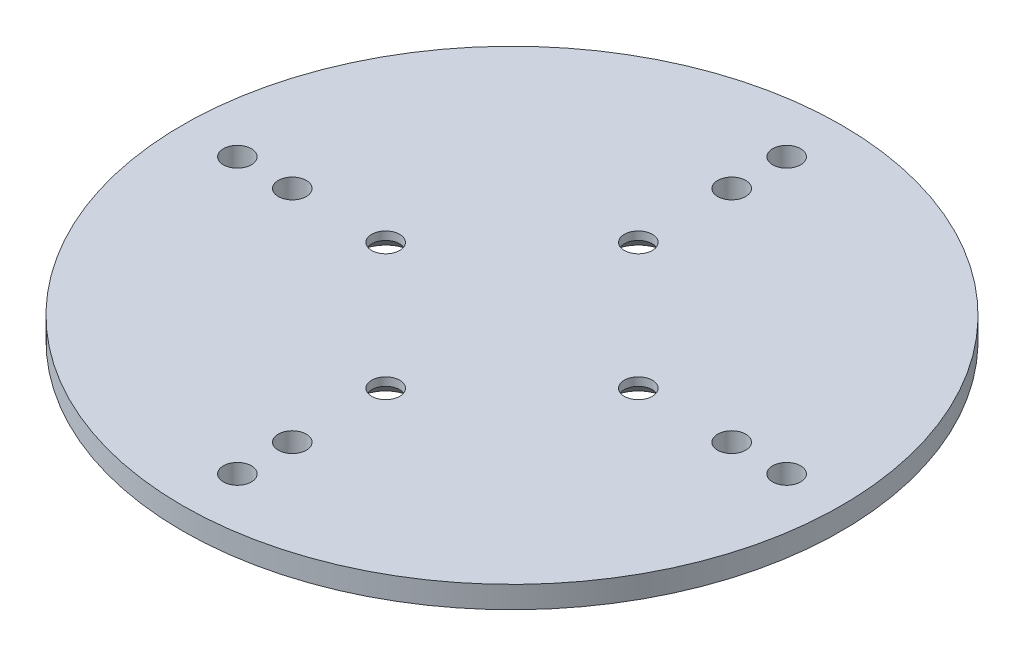
from build123d import *

# Parameters (mm, degrees)
SKETCH_1_R      = 60
SKETCH_1_R_2    = 2.55
EXTRUDE_1_DEPTH = 4
CHAMFER_1_SIZE  = 2.5


with BuildPart() as part:
    # 草图1 → 凸台-拉伸1 (new body)
    with BuildSketch(Plane(origin=(0, 0, 0), x_dir=(1, 0, 0), z_dir=(0, 1, 0))):
        Circle(SKETCH_1_R)
        with Locations((0, 50)):
            Circle(SKETCH_1_R_2, mode=Mode.SUBTRACT)
        with Locations((50, 0)):
            Circle(SKETCH_1_R_2, mode=Mode.SUBTRACT)
        with Locations((0, -50)):
            Circle(SKETCH_1_R_2, mode=Mode.SUBTRACT)
        with Locations((-50, 0)):
            Circle(SKETCH_1_R_2, mode=Mode.SUBTRACT)
        with Locations((0, 40)):
            Circle(SKETCH_1_R_2, mode=Mode.SUBTRACT)
        with Locations((40, 0)):
            Circle(SKETCH_1_R_2, mode=Mode.SUBTRACT)
        with Locations((0, -40)):
            Circle(SKETCH_1_R_2, mode=Mode.SUBTRACT)
        with Locations((-40, 0)):
            Circle(SKETCH_1_R_2, mode=Mode.SUBTRACT)
        with Locations((0, 23)):
            Circle(SKETCH_1_R_2, mode=Mode.SUBTRACT)
        with Locations((23, 0)):
            Circle(SKETCH_1_R_2, mode=Mode.SUBTRACT)
        with Locations((0, -23)):
            Circle(SKETCH_1_R_2, mode=Mode.SUBTRACT)
        with Locations((-23, 0)):
            Circle(SKETCH_1_R_2, mode=Mode.SUBTRACT)
    extrude(amount=EXTRUDE_1_DEPTH)

    # 倒角1
    chamfer_1_edges = [part.edges().sort_by_distance(p)[0] for p in [
        (-2.55, 0, -23),
        (20.45, 0, 0),
        (-2.55, 0, 23),
        (-25.55, 0, 0),
    ]]
    chamfer(chamfer_1_edges, length=CHAMFER_1_SIZE)


solid = part.part
